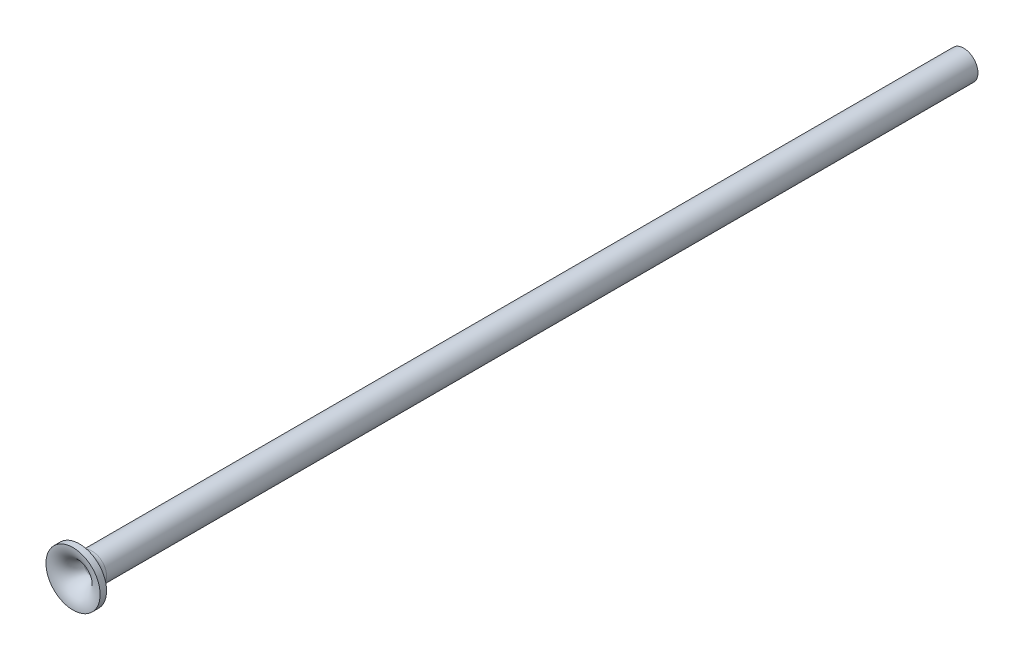
from build123d import *


with BuildPart() as part:
    # Sketch3 → Revolve2 (revolve)
    with BuildSketch(Plane(origin=(0, 0, 0), x_dir=(1, 0, 0), z_dir=(0, 1, 0))):
        with BuildLine():
            Line((-3, -2.125), (-3, -1.4125))
            ThreePointArc((-3, -1.4125), (-2.001211672, -0.998788328), (-1.5875, 0))
            Line((-1.5875, 0), (-1.5875, 96.5))
            Line((-1.5875, 96.5), (-0.875, 96.5))
            Line((-0.875, 96.5), (-0.875, 0))
            ThreePointArc((-0.875, 0), (-1.49739809, -1.50260191), (-3, -2.125))
        make_face()
    revolve(axis=Axis((0, 0, 0), (0, 0, -1)))


solid = part.part
